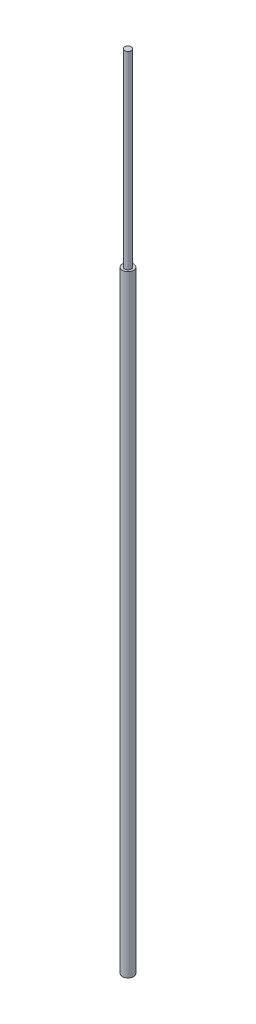
from build123d import *

# Parameters (mm, degrees)
SKETCH1_R           = 12.7
BOSS_EXTRUDE1_DEPTH = 1397
SKETCH2_R           = 7.636992257
BOSS_EXTRUDE2_DEPTH = 431.8


with BuildPart() as part:
    # Sketch1 → Boss-Extrude1 (new body)
    with BuildSketch(Plane(origin=(0, 0, 0), x_dir=(1, 0, 0), z_dir=(0, 1, 0))):
        Circle(SKETCH1_R)
    extrude(amount=BOSS_EXTRUDE1_DEPTH)

    # Sketch2 → Boss-Extrude2 (add)
    with BuildSketch(Plane(origin=(0, 1397, 0), x_dir=(1, 0, 0), z_dir=(0, 1, 0))):
        Circle(SKETCH2_R)
    extrude(amount=BOSS_EXTRUDE2_DEPTH)


solid = part.part
